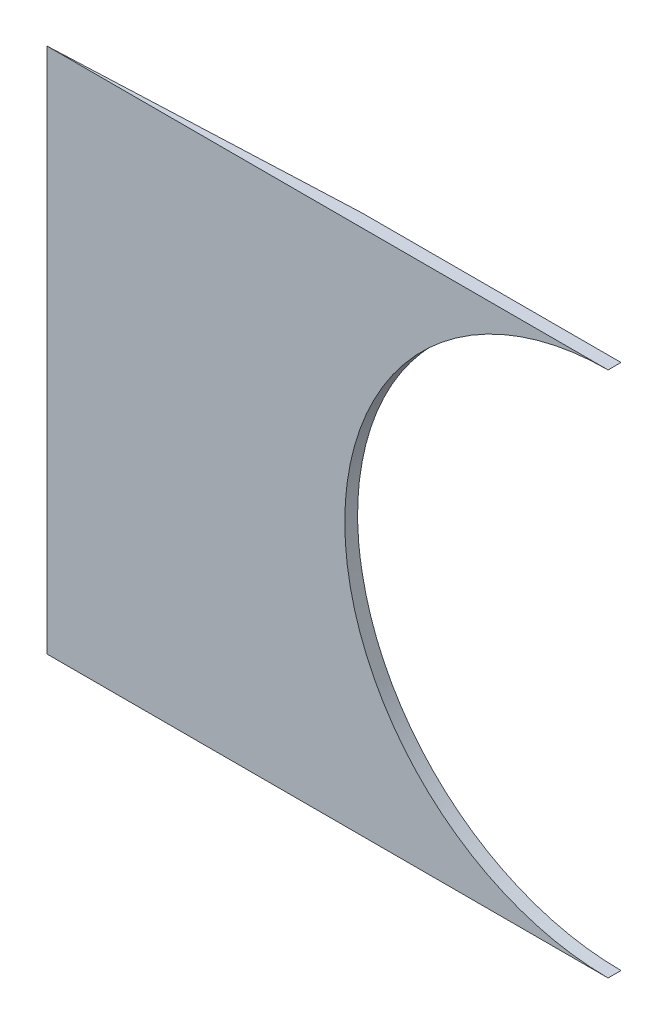
from build123d import *

# Parameters (mm, degrees)
BOSS_EXTRUDE1_DEPTH = 3
CUT_EXTRUDE1_DEPTH  = 123


with BuildPart() as part:
    # Sketch1 → Boss-Extrude1 (new body)
    with BuildSketch(Plane.XY):
        with BuildLine():
            Line((0, 61), (-130, 61))
            Line((-130, 61), (-130, -61))
            Line((-130, -61), (0, -61))
            ThreePointArc((0, -61), (-61, 0), (0, 61))
        make_face()
    extrude(amount=BOSS_EXTRUDE1_DEPTH)

    # Sketch3 → Cut-Extrude1 (cut)
    with BuildSketch(Plane(origin=(0, -61, 0), x_dir=(-1, 0, 0), z_dir=(0, -1, 0))):
        Polygon((130, -3), (60, 0), (130, 0), align=None)
    extrude(amount=-CUT_EXTRUDE1_DEPTH, mode=Mode.SUBTRACT)


solid = part.part
